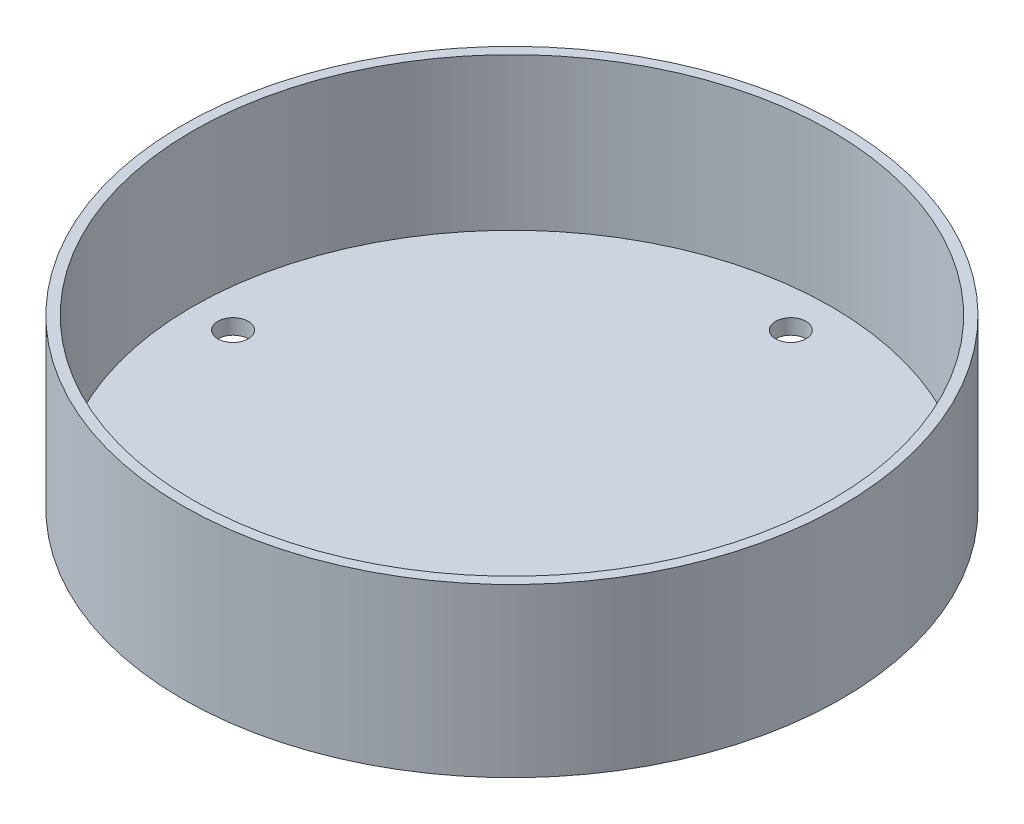
from build123d import *

# Parameters (mm, degrees)
SKETCH1_R           = 65
BOSS_EXTRUDE1_DEPTH = 3
SKETCH2_R           = 3
CUT_EXTRUDE1_DEPTH  = 4
CIRPATTERN1_COUNT   = 4
SKETCH3_R           = 65
SKETCH3_R_2         = 63
BOSS_EXTRUDE2_DEPTH = 30


with BuildPart() as part:
    # Sketch1 → Boss-Extrude1 (new body)
    with BuildSketch(Plane(origin=(0, 0, 0), x_dir=(1, 0, 0), z_dir=(0, 1, 0))):
        Circle(SKETCH1_R)
    extrude(amount=BOSS_EXTRUDE1_DEPTH)

    # Sketch2 → Cut-Extrude1 (cut, through all)
    with BuildSketch(Plane(origin=(0, 3, 0), x_dir=(1, 0, 0), z_dir=(0, 1, 0))):
        with Locations((0, 55)):
            Circle(SKETCH2_R)
    cut_extrude1 = extrude(amount=-CUT_EXTRUDE1_DEPTH, mode=Mode.SUBTRACT)

    # CirPattern1: Cut-Extrude1 ×4 about axis
    cirpattern1_axis = Axis((0, 0, 0), (0, 1, 0))
    for i in range(1, CIRPATTERN1_COUNT):
        add(cut_extrude1.rotate(cirpattern1_axis, i * 360 / CIRPATTERN1_COUNT), mode=Mode.SUBTRACT)

    # Sketch3 → Boss-Extrude2 (add)
    with BuildSketch(Plane(origin=(0, 3, 0), x_dir=(1, 0, 0), z_dir=(0, 1, 0))):
        Circle(SKETCH3_R)
        Circle(SKETCH3_R_2, mode=Mode.SUBTRACT)
    extrude(amount=BOSS_EXTRUDE2_DEPTH)


solid = part.part
